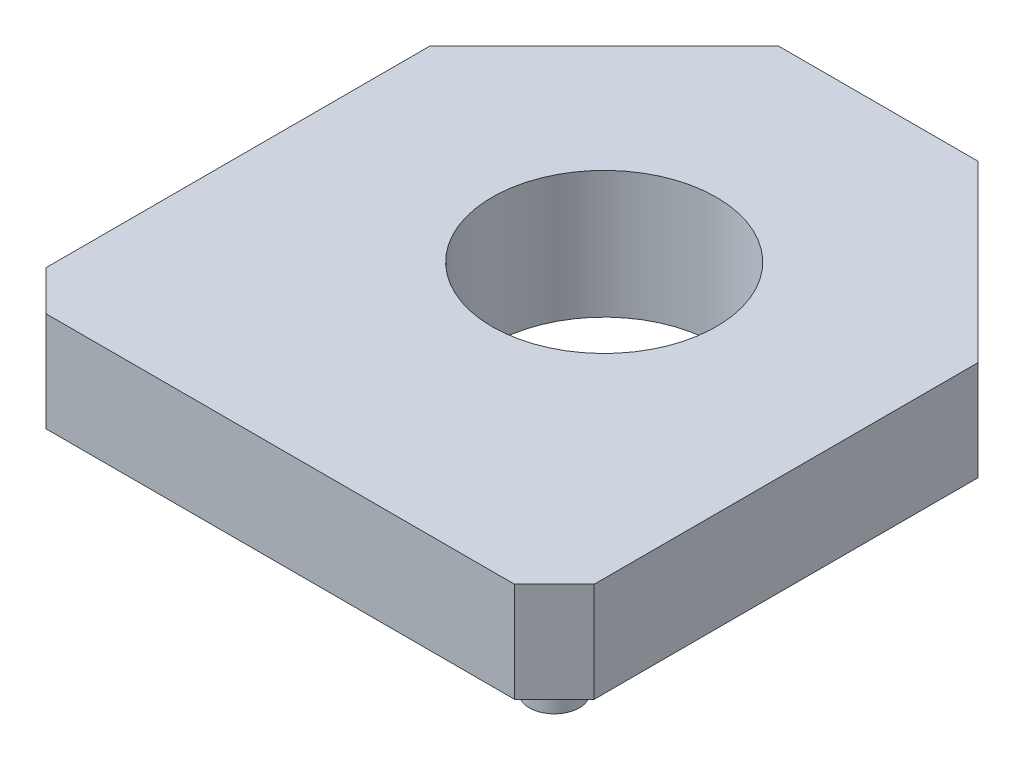
from build123d import *

# Parameters (mm, degrees)
SKETCH1_R           = 2.25
BOSS_EXTRUDE1_DEPTH = 2
SKETCH2_R           = 2.5
SKETCH2_R_2         = 2.25
BOSS_EXTRUDE2_DEPTH = 0.55
SKETCH3_R           = 0.5
BOSS_EXTRUDE3_DEPTH = 1


with BuildPart() as part:
    # Sketch1 → Boss-Extrude1 (new body)
    with BuildSketch(Plane(origin=(0, 0, 0), x_dir=(1, 0, 0), z_dir=(0, 1, 0))):
        Polygon((-17.906062461, 15.839978331), (-17.906062461, 23.539978331), (-14.406062461, 27.039978331), (-10.406062461, 27.039978331), (-6.906062461, 23.539978331), (-6.906062461, 15.839978331), (-7.706062461, 15.039978331), (-17.106062461, 15.039978331), align=None)
        with Locations((-12.406062461, 21.539978331)):
            Circle(SKETCH1_R, mode=Mode.SUBTRACT)
    extrude(amount=BOSS_EXTRUDE1_DEPTH)

    # Sketch2 → Boss-Extrude2 (add)
    with BuildSketch(Plane.XZ):
        with Locations((-12.406062461, -21.539978331)):
            Circle(SKETCH2_R)
        with Locations((-12.406062461, -21.539978331)):
            Circle(SKETCH2_R_2, mode=Mode.SUBTRACT)
    extrude(amount=BOSS_EXTRUDE2_DEPTH)

    # Sketch3 → Boss-Extrude3 (add)
    with BuildSketch(Plane.XZ):
        with Locations((-16.406062461, -16.539978331)):
            Circle(SKETCH3_R)
        with Locations((-8.406062461, -16.539978331)):
            Circle(SKETCH3_R)
    extrude(amount=BOSS_EXTRUDE3_DEPTH)


solid = part.part
